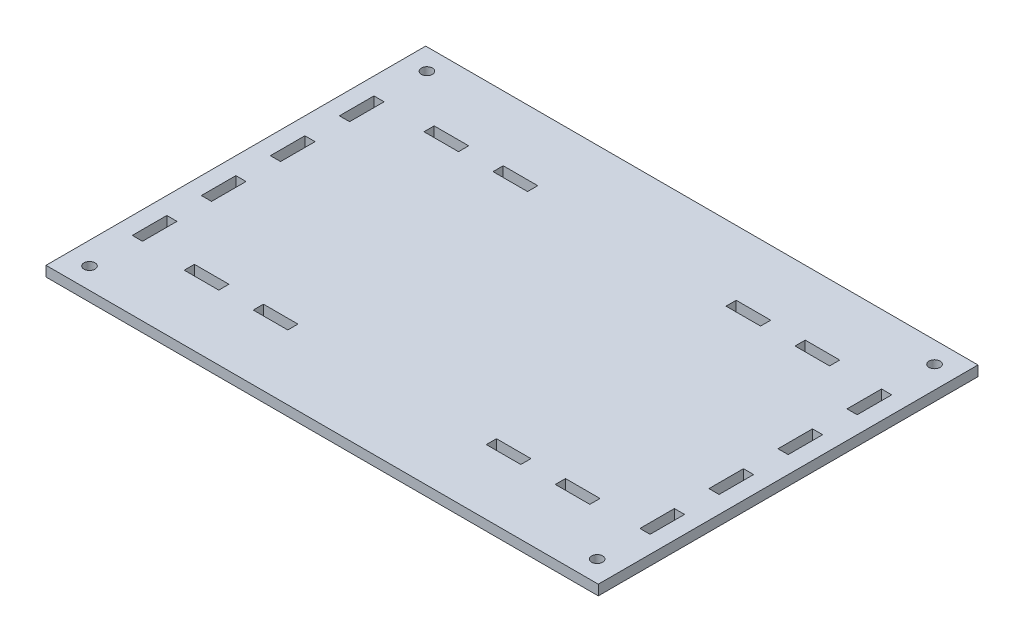
from build123d import *

# Parameters (mm, degrees)
SKETCH1_W               = 160
SKETCH1_H               = 110
BOSS_EXTRUDE1_DEPTH     = 2.95
SKETCH2_W               = 10
SKETCH2_H               = 2.95
CUT_EXTRUDE1_DEPTH      = 3.95
LPATTERN2_COUNT         = 2
LPATTERN2_PITCH         = 20
MIRROR1_COPY_1_SKETCH_W = 10
MIRROR1_COPY_1_SKETCH_H = 2.95
MIRROR1_COPY_1_DEPTH    = 3.95
MIRROR2_COPY_1_SKETCH_W = 10
MIRROR2_COPY_1_SKETCH_H = 2.95
MIRROR2_COPY_1_DEPTH    = 3.95
MIRROR2_COPY_2_SKETCH_W = 10
MIRROR2_COPY_2_SKETCH_H = 2.95
MIRROR2_COPY_2_DEPTH    = 3.95
MIRROR2_COPY_3_SKETCH_W = 10
MIRROR2_COPY_3_SKETCH_H = 2.95
MIRROR2_COPY_3_DEPTH    = 3.95
SKETCH4_W               = 2.95
SKETCH4_H               = 10
CUT_EXTRUDE2_DEPTH      = 3.95
LPATTERN3_COUNT         = 3
LPATTERN3_PITCH         = 20
MIRROR4_COPY_1_SKETCH_W = 2.95
MIRROR4_COPY_1_SKETCH_H = 10
MIRROR4_COPY_1_DEPTH    = 3.95
MIRROR5_COPY_1_SKETCH_W = 2.95
MIRROR5_COPY_1_SKETCH_H = 10
MIRROR5_COPY_1_DEPTH    = 3.95
MIRROR5_COPY_2_SKETCH_W = 2.95
MIRROR5_COPY_2_SKETCH_H = 10
MIRROR5_COPY_2_DEPTH    = 3.95
MIRROR5_COPY_3_SKETCH_W = 2.95
MIRROR5_COPY_3_SKETCH_H = 10
MIRROR5_COPY_3_DEPTH    = 3.95
M3_CLEARANCE_HOLE1_D    = 3.2
MIRROR7_COPY_1_D        = 3.2


with BuildPart() as part:
    # Sketch1 → Boss-Extrude1 (new body)
    with BuildSketch(Plane(origin=(0, 0, 0), x_dir=(1, 0, 0), z_dir=(0, 1, 0))):
        Rectangle(SKETCH1_W, SKETCH1_H)
    extrude(amount=BOSS_EXTRUDE1_DEPTH)

    # Sketch2 → Cut-Extrude1 (cut, through all)
    with BuildSketch(Plane(origin=(0, 2.95, 0), x_dir=(1, 0, 0), z_dir=(0, 1, 0))):
        with Locations((-53.75, 34.729)):
            Rectangle(SKETCH2_W, SKETCH2_H)
    cut_extrude1 = extrude(amount=-CUT_EXTRUDE1_DEPTH, mode=Mode.SUBTRACT)

    # LPattern2: Cut-Extrude1 ×2
    with Locations(*[(i * LPATTERN2_PITCH, 0, 0) for i in range(1, LPATTERN2_COUNT)]):
        add(cut_extrude1, mode=Mode.SUBTRACT)

    # Mirror1: Cut-Extrude1 across plane
    add(cut_extrude1.mirror(Plane.XY), mode=Mode.SUBTRACT)

    # Mirror1 copy 1 sketch → Mirror1 copy 1 (cut, through all)
    with BuildSketch(Plane(origin=(20, 2.95, 0), x_dir=(1, 0, 0), z_dir=(0, 1, 0))):
        with Locations((-53.75, -34.729)):
            Rectangle(MIRROR1_COPY_1_SKETCH_W, MIRROR1_COPY_1_SKETCH_H)
    extrude(amount=-MIRROR1_COPY_1_DEPTH, mode=Mode.SUBTRACT)

    # Mirror2: Cut-Extrude1 across plane
    add(cut_extrude1.mirror(Plane(origin=(0, 0, 0), x_dir=(0, 0, 1), z_dir=(1, 0, 0))), mode=Mode.SUBTRACT)

    # Mirror2 copy 1 sketch → Mirror2 copy 1 (cut, through all)
    with BuildSketch(Plane(origin=(0, 2.95, 0), x_dir=(-1, 0, 0), z_dir=(0, 1, 0))):
        with Locations((-53.75, 34.729)):
            Rectangle(MIRROR2_COPY_1_SKETCH_W, MIRROR2_COPY_1_SKETCH_H)
    extrude(amount=-MIRROR2_COPY_1_DEPTH, mode=Mode.SUBTRACT)

    # Mirror2 copy 2 sketch → Mirror2 copy 2 (cut, through all)
    with BuildSketch(Plane(origin=(-20, 2.95, 0), x_dir=(-1, 0, 0), z_dir=(0, 1, 0))):
        with Locations((-53.75, 34.729)):
            Rectangle(MIRROR2_COPY_2_SKETCH_W, MIRROR2_COPY_2_SKETCH_H)
    extrude(amount=-MIRROR2_COPY_2_DEPTH, mode=Mode.SUBTRACT)

    # Mirror2 copy 3 sketch → Mirror2 copy 3 (cut, through all)
    with BuildSketch(Plane(origin=(-20, 2.95, 0), x_dir=(-1, 0, 0), z_dir=(0, 1, 0))):
        with Locations((-53.75, -34.729)):
            Rectangle(MIRROR2_COPY_3_SKETCH_W, MIRROR2_COPY_3_SKETCH_H)
    extrude(amount=-MIRROR2_COPY_3_DEPTH, mode=Mode.SUBTRACT)

    # Sketch4 → Cut-Extrude2 (cut, through all)
    with BuildSketch(Plane(origin=(0, 2.95, 0), x_dir=(1, 0, 0), z_dir=(0, 1, 0))):
        with Locations((-73.525, 10)):
            Rectangle(SKETCH4_W, SKETCH4_H)
    cut_extrude2 = extrude(amount=-CUT_EXTRUDE2_DEPTH, mode=Mode.SUBTRACT)

    # LPattern3: Cut-Extrude2 ×3, 1 skipped
    with Locations(*[(0, 0, -i * LPATTERN3_PITCH) for i in range(1, LPATTERN3_COUNT) if i not in (2,)]):
        add(cut_extrude2, mode=Mode.SUBTRACT)

    # Mirror4: Cut-Extrude2 across plane
    add(cut_extrude2.mirror(Plane.XY), mode=Mode.SUBTRACT)

    # Mirror4 copy 1 sketch → Mirror4 copy 1 (cut, through all)
    with BuildSketch(Plane(origin=(0, 2.95, 20), x_dir=(1, 0, 0), z_dir=(0, 1, 0))):
        with Locations((-73.525, -10)):
            Rectangle(MIRROR4_COPY_1_SKETCH_W, MIRROR4_COPY_1_SKETCH_H)
    extrude(amount=-MIRROR4_COPY_1_DEPTH, mode=Mode.SUBTRACT)

    # Mirror5: Cut-Extrude2 across plane
    add(cut_extrude2.mirror(Plane(origin=(0, 0, 0), x_dir=(0, 0, 1), z_dir=(1, 0, 0))), mode=Mode.SUBTRACT)

    # Mirror5 copy 1 sketch → Mirror5 copy 1 (cut, through all)
    with BuildSketch(Plane(origin=(0, 2.95, 0), x_dir=(-1, 0, 0), z_dir=(0, 1, 0))):
        with Locations((-73.525, 10)):
            Rectangle(MIRROR5_COPY_1_SKETCH_W, MIRROR5_COPY_1_SKETCH_H)
    extrude(amount=-MIRROR5_COPY_1_DEPTH, mode=Mode.SUBTRACT)

    # Mirror5 copy 2 sketch → Mirror5 copy 2 (cut, through all)
    with BuildSketch(Plane(origin=(0, 2.95, 20), x_dir=(-1, 0, 0), z_dir=(0, 1, 0))):
        with Locations((-73.525, 10)):
            Rectangle(MIRROR5_COPY_2_SKETCH_W, MIRROR5_COPY_2_SKETCH_H)
    extrude(amount=-MIRROR5_COPY_2_DEPTH, mode=Mode.SUBTRACT)

    # Mirror5 copy 3 sketch → Mirror5 copy 3 (cut, through all)
    with BuildSketch(Plane(origin=(0, 2.95, -20), x_dir=(-1, 0, 0), z_dir=(0, 1, 0))):
        with Locations((-73.525, -10)):
            Rectangle(MIRROR5_COPY_3_SKETCH_W, MIRROR5_COPY_3_SKETCH_H)
    extrude(amount=-MIRROR5_COPY_3_DEPTH, mode=Mode.SUBTRACT)

    # M3 Clearance Hole1 (through all)
    with Locations(Plane(origin=(0, 2.95, 0), x_dir=(1, 0, 0), z_dir=(0, 1, 0))):
        with Locations((-73.525, 48.875)):
            m3_clearance_hole1 = Hole(M3_CLEARANCE_HOLE1_D / 2)

    # Mirror6: M3 Clearance Hole1 across plane
    add(m3_clearance_hole1.mirror(Plane.XY), mode=Mode.SUBTRACT)

    # Mirror7: M3 Clearance Hole1 across plane
    add(m3_clearance_hole1.mirror(Plane(origin=(0, 0, 0), x_dir=(0, 0, 1), z_dir=(1, 0, 0))), mode=Mode.SUBTRACT)

    # Mirror7 copy 1 (through all)
    with Locations(Plane(origin=(0, 2.95, 0), x_dir=(-1, 0, 0), z_dir=(0, 1, 0))):
        with Locations((-73.525, 48.875)):
            Hole(MIRROR7_COPY_1_D / 2)


solid = part.part
